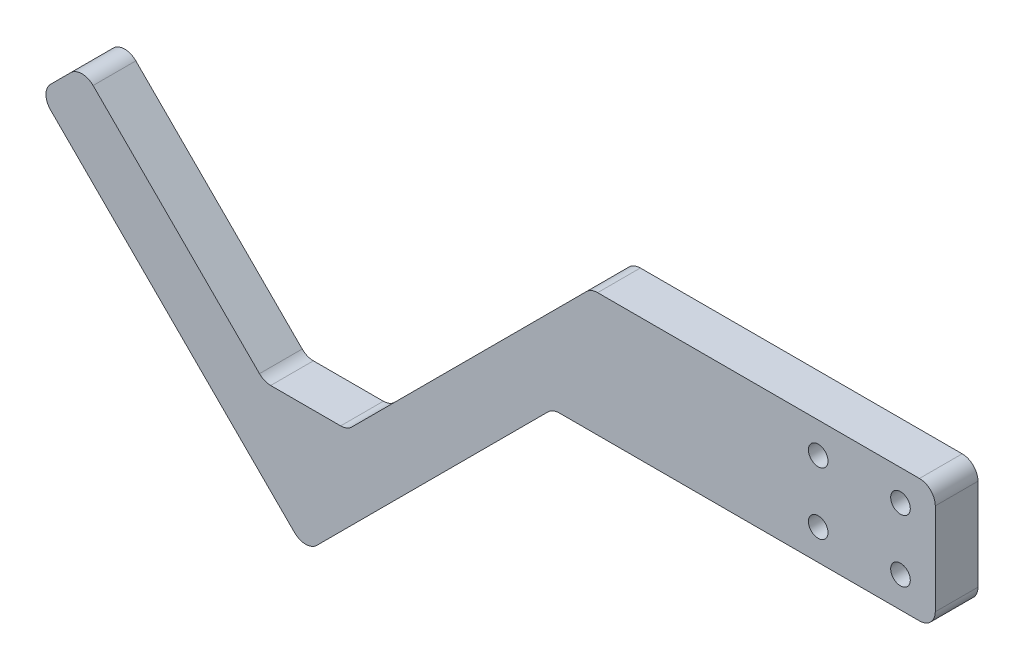
from build123d import *

# Parameters (mm, degrees)
SKETCH1_R           = 3.1
BOSS_EXTRUDE1_DEPTH = 13.5
FILLET1_R           = 5


with BuildPart() as part:
    # Sketch1 → Boss-Extrude1 (new body)
    with BuildSketch(Plane.XY):
        Polygon((13.129942315, -57.580735804), (-13.129942315, -57.580735804), (0, -70.710678119), align=None)
        Polygon((0, -70.710678119), (90.210678119, 19.5), (199, 19.5), (199, -19.5), (78.080735804, -19.5), (0, -97.580735804), (-84.145706961, -13.435028843), (-70.710678119, 0), align=None)
        with Locations((188, -9.8)):
            Circle(SKETCH1_R, mode=Mode.SUBTRACT)
        with Locations((162, -9.8)):
            Circle(SKETCH1_R, mode=Mode.SUBTRACT)
        with Locations((162, 9.8)):
            Circle(SKETCH1_R, mode=Mode.SUBTRACT)
        with Locations((188, 9.8)):
            Circle(SKETCH1_R, mode=Mode.SUBTRACT)
    extrude(amount=BOSS_EXTRUDE1_DEPTH)

    # Fillet1
    fillet1_edges = [part.edges().sort_by_distance(p)[0] for p in [
        (13.129942315, -57.580735804, 6.75),
        (90.210678119, 19.5, 6.75),
        (199, 19.5, 6.75),
        (199, -19.5, 6.75),
        (78.080735804, -19.5, 6.75),
        (0, -97.580735804, 6.75),
        (-84.145706961, -13.435028843, 6.75),
        (-70.710678119, 0, 6.75),
        (-13.129942315, -57.580735804, 6.75),
    ]]
    fillet(fillet1_edges, radius=FILLET1_R)


solid = part.part
